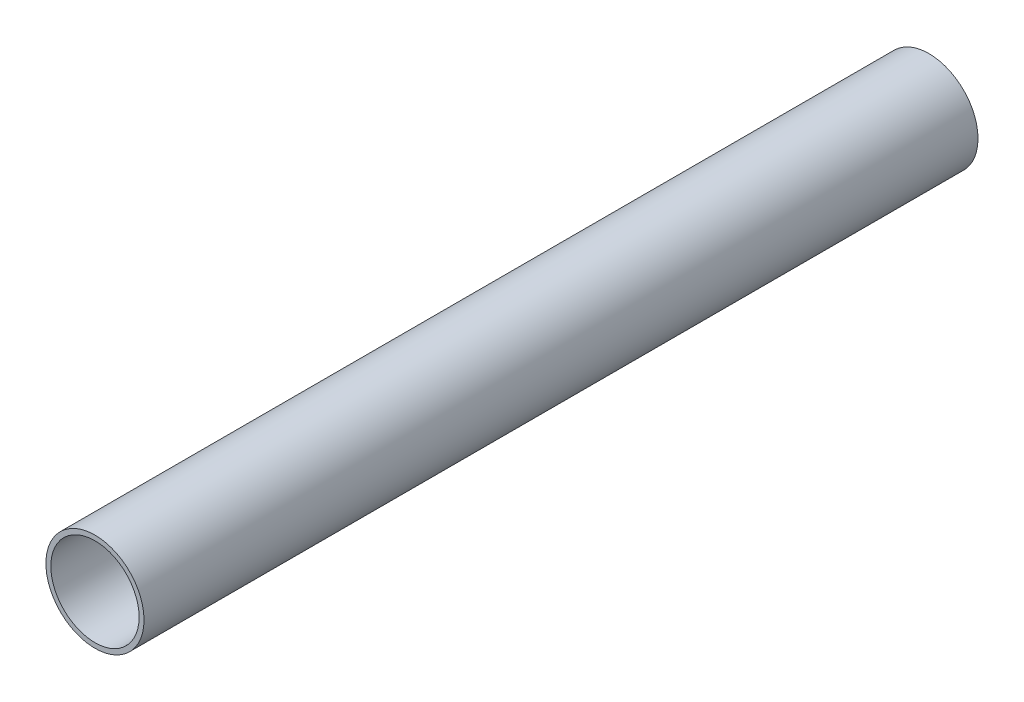
from build123d import *

# Parameters (mm, degrees)
SKETCH1_R           = 10
SKETCH1_R_2         = 9
BOSS_EXTRUDE1_DEPTH = 170


with BuildPart() as part:
    # Sketch1 → Boss-Extrude1 (new body)
    with BuildSketch(Plane.XY):
        Circle(SKETCH1_R)
        Circle(SKETCH1_R_2, mode=Mode.SUBTRACT)
    extrude(amount=BOSS_EXTRUDE1_DEPTH)


solid = part.part
